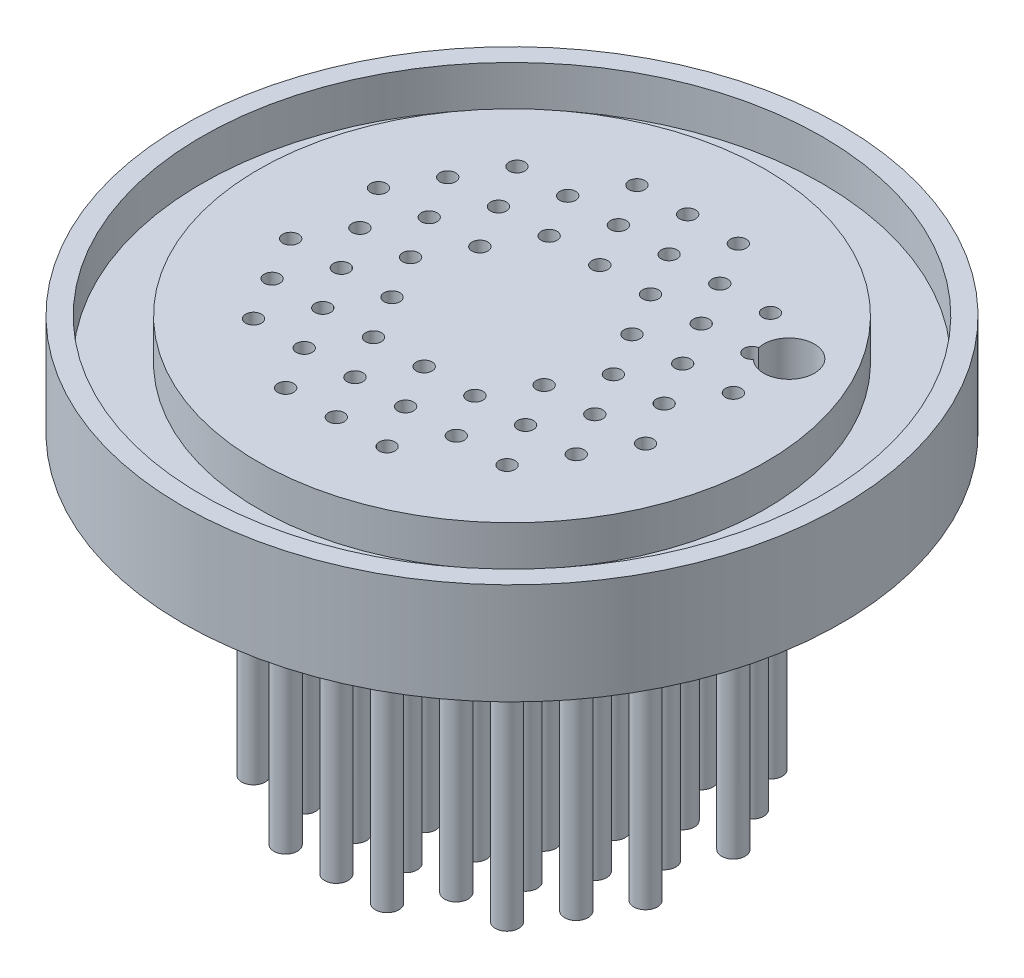
from build123d import *

# Parameters (mm, degrees)
F_1_8_0_125_DIAMETER_HOLE1_D = 3.175
SKETCH9_R                    = 0.7366
SKETCH9_R_2                  = 0.4953
BOSS_EXTRUDE1_DEPTH          = 18.415
SKETCH9_2_R                  = 0.4953
CUT_EXTRUDE1_DEPTH           = 35.509781765
CIRPATTERN4_COUNT            = 6


with BuildPart() as part:
    # Sketch1 → Revolve1 (revolve)
    with BuildSketch(Plane.XY):
        Polygon((-15.875, 6.35), (-15.875, 3.81), (-19.431, 3.81), (-19.431, 6.35), (-20.6375, 6.35), (-20.6375, 0), (0, 0), (0, 6.35), align=None)
    revolve(axis=Axis((0, 0, 0), (0, 1, 0)))

    # 1_8 _0.125_ Diameter Hole1 (through all)
    with Locations(Plane(origin=(0, 6.35, 0), x_dir=(1, 0, 0), z_dir=(0, 1, 0))):
        with Locations((10.998522628, 6.35)):
            Hole(F_1_8_0_125_DIAMETER_HOLE1_D / 2)

    # Sketch9 → Boss-Extrude1 (add)
    # profile 1 of 8: a face of its own
    with BuildSketch(Plane.XZ):
        with Locations((3.175, 10.998522628)):
            Circle(SKETCH9_R)
        with Locations((3.175, 10.998522628)):
            Circle(SKETCH9_R_2, mode=Mode.SUBTRACT)
    # profile 2 of 8: a face of its own
    with BuildSketch(Plane.XZ):
        with Locations((0, 10.998522628)):
            Circle(SKETCH9_R)
        with Locations((0, 10.998522628)):
            Circle(SKETCH9_R_2, mode=Mode.SUBTRACT)
    # profile 3 of 8: a face of its own
    with BuildSketch(Plane.XZ):
        with Locations((1.5875, 8.248891971)):
            Circle(SKETCH9_R)
        with Locations((1.5875, 8.248891971)):
            Circle(SKETCH9_R_2, mode=Mode.SUBTRACT)
    # profile 4 of 8: a face of its own
    with BuildSketch(Plane.XZ):
        with Locations((0, 5.499261314)):
            Circle(SKETCH9_R)
        with Locations((0, 5.499261314)):
            Circle(SKETCH9_R_2, mode=Mode.SUBTRACT)
    # profile 5 of 8: a face of its own
    with BuildSketch(Plane.XZ):
        with Locations((-3.175, 5.499261314)):
            Circle(SKETCH9_R)
        with Locations((-3.175, 5.499261314)):
            Circle(SKETCH9_R_2, mode=Mode.SUBTRACT)
    # profile 6 of 8: a face of its own
    with BuildSketch(Plane.XZ):
        with Locations((-4.7625, 8.248891971)):
            Circle(SKETCH9_R)
        with Locations((-4.7625, 8.248891971)):
            Circle(SKETCH9_R_2, mode=Mode.SUBTRACT)
    # profile 7 of 8: a face of its own
    with BuildSketch(Plane.XZ):
        with Locations((-3.175, 10.998522628)):
            Circle(SKETCH9_R)
        with Locations((-3.175, 10.998522628)):
            Circle(SKETCH9_R_2, mode=Mode.SUBTRACT)
    # profile 8 of 8: a face of its own
    with BuildSketch(Plane.XZ):
        with Locations((-1.5875, 8.248891971)):
            Circle(SKETCH9_R)
        with Locations((-1.5875, 8.248891971)):
            Circle(SKETCH9_R_2, mode=Mode.SUBTRACT)
    boss_extrude1 = extrude(amount=BOSS_EXTRUDE1_DEPTH)

    # Sketch9_2 → Cut-Extrude1 (cut, through all)
    with BuildSketch(Plane.XZ):
        with Locations((3.175, 10.998522628)):
            Circle(SKETCH9_2_R)
        with Locations((0, 10.998522628)):
            Circle(SKETCH9_2_R)
        with Locations((1.5875, 8.248891971)):
            Circle(SKETCH9_2_R)
        with Locations((0, 5.499261314)):
            Circle(SKETCH9_2_R)
        with Locations((-3.175, 5.499261314)):
            Circle(SKETCH9_2_R)
        with Locations((-4.7625, 8.248891971)):
            Circle(SKETCH9_2_R)
        with Locations((-3.175, 10.998522628)):
            Circle(SKETCH9_2_R)
        with Locations((-1.5875, 8.248891971)):
            Circle(SKETCH9_2_R)
    cut_extrude1 = extrude(amount=-CUT_EXTRUDE1_DEPTH, mode=Mode.SUBTRACT)

    # CirPattern4: Boss-Extrude1, Cut-Extrude1 ×6 about axis
    cirpattern4_axis = Axis((0, 7.5565, 0), (0, -1, 0))
    add([boss_extrude1.rotate(cirpattern4_axis, i * 360 / CIRPATTERN4_COUNT) for i in range(1, CIRPATTERN4_COUNT)])
    add([cut_extrude1.rotate(cirpattern4_axis, i * 360 / CIRPATTERN4_COUNT) for i in range(1, CIRPATTERN4_COUNT)], mode=Mode.SUBTRACT)


solid = part.part
